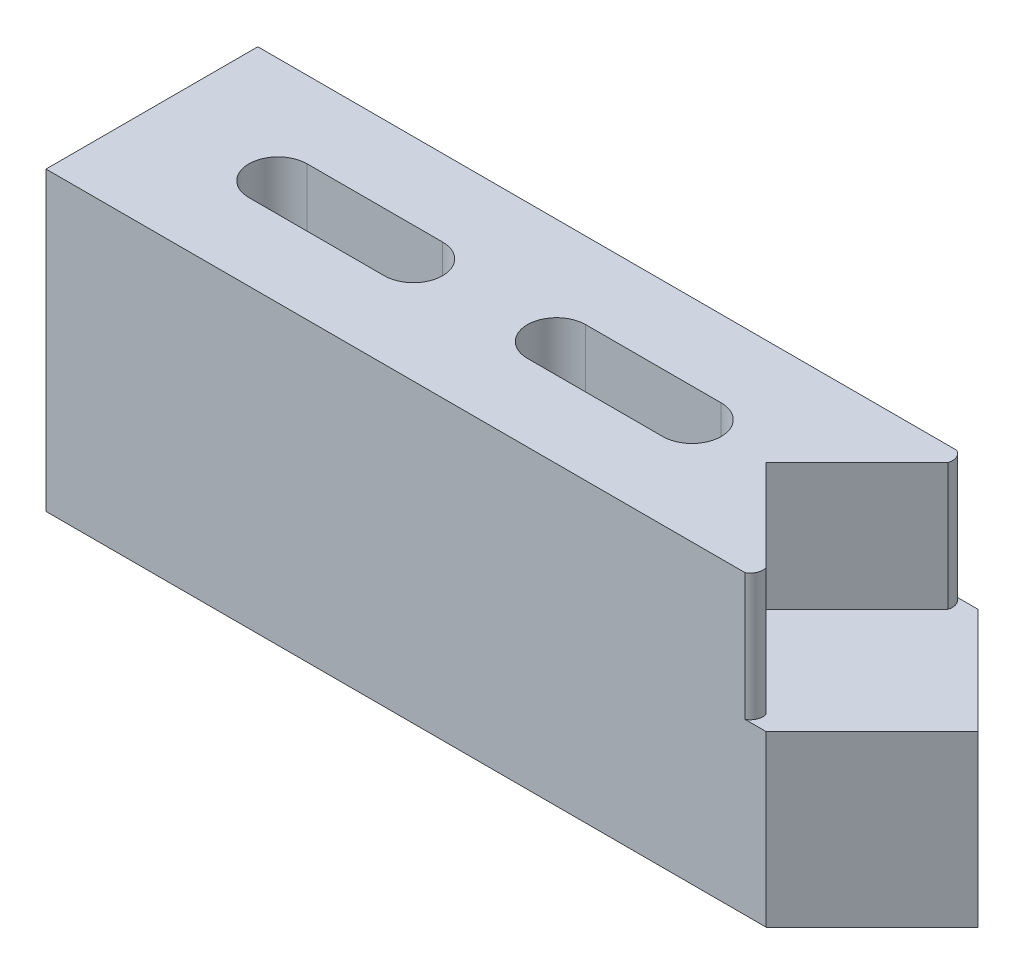
from build123d import *

# Parameters (mm, degrees)
SKETCH1_W           = 43.18
SKETCH1_H           = 17.78
BOSS_EXTRUDE1_DEPTH = 12.7
CUT_EXTRUDE1_DEPTH  = 7.62
CUT_EXTRUDE2_DEPTH  = 18.78
BOSS_EXTRUDE2_DEPTH = 10.16
CUT_EXTRUDE3_DEPTH  = 7.62


with BuildPart() as part:
    # Sketch1 → Boss-Extrude1 (new body)
    with BuildSketch(Plane.XY):
        with Locations((21.59, 8.89)):
            Rectangle(SKETCH1_W, SKETCH1_H)
    extrude(amount=-BOSS_EXTRUDE1_DEPTH)

    # Sketch3 → Cut-Extrude1 (cut)
    with BuildSketch(Plane(origin=(0, 17.78, 0), x_dir=(1, 0, 0), z_dir=(0, 1, 0))):
        Polygon((43.18, 12.7), (36.83, 6.35), (43.18, 0), align=None)
    extrude(amount=-CUT_EXTRUDE1_DEPTH, mode=Mode.SUBTRACT)

    # Sketch4 → Cut-Extrude2 (cut, through all)
    with BuildSketch(Plane(origin=(0, 17.78, 0), x_dir=(1, 0, 0), z_dir=(0, 1, 0))):
        with BuildLine():
            Line((32.381000008, 4.599999944), (24.260999992, 4.599999944))
            ThreePointArc((24.260999992, 4.599999944), (22.510999936, 6.35), (24.260999992, 8.100000056))
            Line((24.260999992, 8.100000056), (32.381000008, 8.100000056))
            ThreePointArc((32.381000008, 8.100000056), (34.131000064, 6.35), (32.381000008, 4.599999944))
        make_face()
        with BuildLine():
            Line((15.68099988, 4.599999944), (7.560999864, 4.599999944))
            ThreePointArc((7.560999864, 4.599999944), (5.810999808, 6.35), (7.560999864, 8.100000056))
            Line((7.560999864, 8.100000056), (15.68099988, 8.100000056))
            ThreePointArc((15.68099988, 8.100000056), (17.430999936, 6.35), (15.68099988, 4.599999944))
        make_face()
    extrude(amount=-CUT_EXTRUDE2_DEPTH, mode=Mode.SUBTRACT)

    # Sketch5 → Boss-Extrude2 (add)
    with BuildSketch(Plane(origin=(0, 10.16, 0), x_dir=(1, 0, 0), z_dir=(0, 1, 0))):
        Polygon((43.18, 12.7), (49.53, 6.35), (43.18, 0), align=None)
    extrude(amount=-BOSS_EXTRUDE2_DEPTH)

    # Sketch6 → Cut-Extrude3 (cut)
    with BuildSketch(Plane(origin=(0, 17.78, 0), x_dir=(1, 0, 0), z_dir=(0, 1, 0))):
        with BuildLine():
            Line((41.91, 12.7), (43.18, 12.7))
            Line((43.18, 12.7), (42.281974388, 11.801974388))
            ThreePointArc((42.281974388, 11.801974388), (42.257767431, 12.317998762), (41.91, 12.7))
        make_face()
        with BuildLine():
            Line((41.91, 0), (43.18, 0))
            Line((43.18, 0), (42.281974388, 0.898025612))
            ThreePointArc((42.281974388, 0.898025612), (42.257767431, 0.382001238), (41.91, 0))
        make_face()
    extrude(amount=-CUT_EXTRUDE3_DEPTH, mode=Mode.SUBTRACT)


solid = part.part
